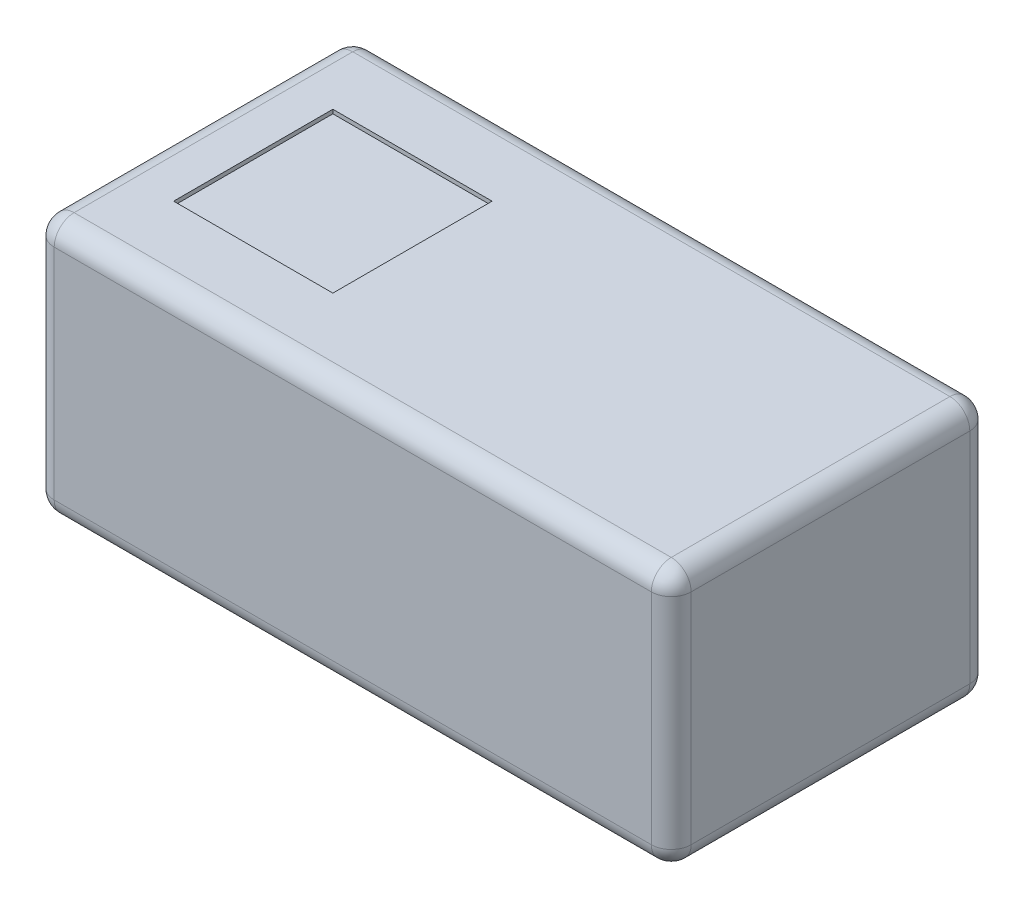
from build123d import *

# Parameters (mm, degrees)
SKETCH1_W           = 1.6
SKETCH1_H           = 0.8
BOSS_EXTRUDE1_DEPTH = 0.65
SKETCH2_W           = 0.23
SKETCH2_H           = 0.65
SKETCH2_W_2         = 0.408711406
SKETCH2_H_2         = 0.22
BOSS_EXTRUDE2_DEPTH = 0.01
FILLET1_R           = 0.05
SKETCH3_W           = 0.4
SKETCH3_H           = 0.4
CUT_EXTRUDE1_DEPTH  = 0.01


with BuildPart() as part:
    # Sketch1 → Boss-Extrude1 (new body)
    with BuildSketch(Plane(origin=(0, 0, 0), x_dir=(1, 0, 0), z_dir=(0, 1, 0))):
        Rectangle(SKETCH1_W, SKETCH1_H)
    extrude(amount=BOSS_EXTRUDE1_DEPTH)

    # Sketch2 → Boss-Extrude2 (add)
    with BuildSketch(Plane.XZ):
        with Locations((-0.619355703, 0)):
            Rectangle(SKETCH2_W, SKETCH2_H)
        with Locations((0.619355703, 0)):
            Rectangle(SKETCH2_W, SKETCH2_H)
        with Locations((0, -0.215)):
            Rectangle(SKETCH2_W_2, SKETCH2_H_2)
        with Locations((0, 0.215)):
            Rectangle(SKETCH2_W_2, SKETCH2_H_2)
    extrude(amount=BOSS_EXTRUDE2_DEPTH)

    # Fillet1
    fillet1_edges = [part.edges().sort_by_distance(p)[0] for p in [
        (-0.8, 0.65, 0),
        (0, 0.65, 0.4),
        (0.8, 0.65, 0),
        (0, 0, 0.4),
        (-0.8, 0, 0),
        (0, 0, -0.4),
        (0.8, 0, 0),
        (0.8, 0.325, 0.4),
        (-0.8, 0.325, 0.4),
        (-0.8, 0.325, -0.4),
        (0.8, 0.325, -0.4),
        (0, 0.65, -0.4),
    ]]
    fillet(fillet1_edges, radius=FILLET1_R)

    # Sketch3 → Cut-Extrude1 (cut)
    with BuildSketch(Plane(origin=(0, 0.65, 0), x_dir=(1, 0, 0), z_dir=(0, 1, 0))):
        with Locations((-0.45, 0)):
            Rectangle(SKETCH3_W, SKETCH3_H)
    extrude(amount=-CUT_EXTRUDE1_DEPTH, mode=Mode.SUBTRACT)


solid = part.part
